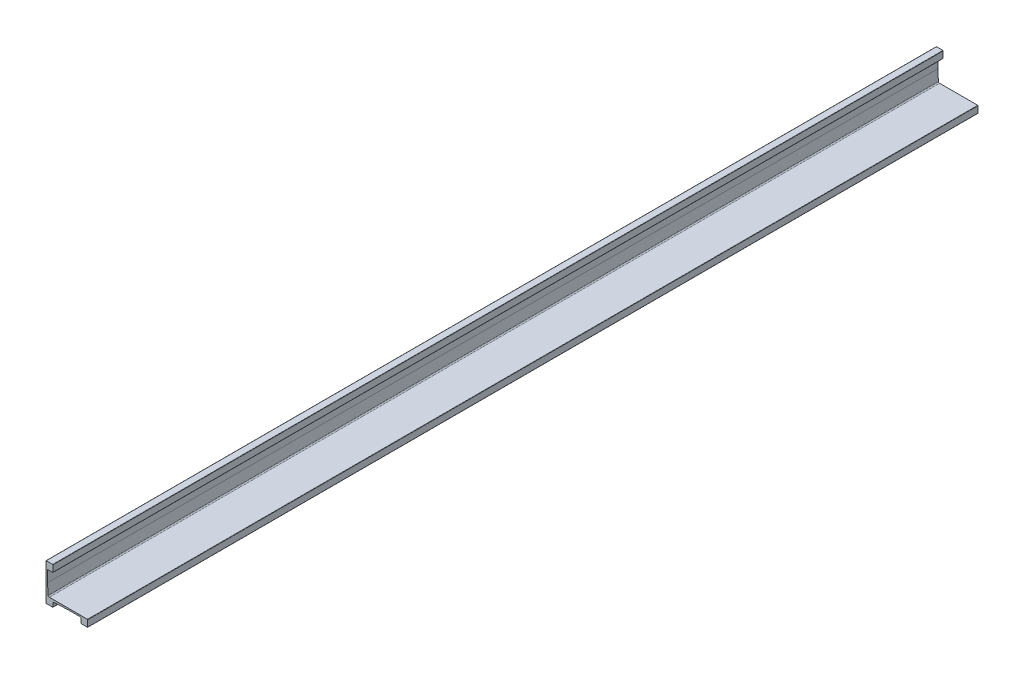
from build123d import *

# Parameters (mm, degrees)
BOSS_EXTRUDE1_DEPTH = 1219.2
FILLET1_R           = 0.381
FILLET2_R           = 1.5875


with BuildPart() as part:
    # Sketch2 → Boss-Extrude1 (new body)
    with BuildSketch(Plane.XY):
        Polygon((0, 0), (0, 50.8), (9.525, 50.8), (9.525, 41.275), (2.032, 41.275), (2.032, 25.4), (3.0734, 9.525), (57.15, 9.525), (57.15, 0), (47.625, 0), (47.625, 7.493), (28.575, 7.493), (9.525, 6.4516), (9.525, 0), align=None)
    extrude(amount=BOSS_EXTRUDE1_DEPTH)

    # Fillet1
    fillet1_edges = [part.edges().sort_by_distance(p)[0] for p in [
        (0, 0, 609.6),
        (0, 50.8, 609.6),
        (9.525, 50.8, 609.6),
        (9.525, 41.275, 609.6),
        (2.032, 41.275, 609.6),
        (57.15, 9.525, 609.6),
        (57.15, 0, 609.6),
        (47.625, 0, 609.6),
        (47.625, 7.493, 609.6),
        (9.525, 0, 609.6),
    ]]
    fillet(fillet1_edges, radius=FILLET1_R)

    # Fillet2
    fillet2_edges = [part.edges().sort_by_distance(p)[0] for p in [
        (3.0734, 9.525, 609.6),
        (9.525, 6.4516, 609.6),
    ]]
    fillet(fillet2_edges, radius=FILLET2_R)


solid = part.part
